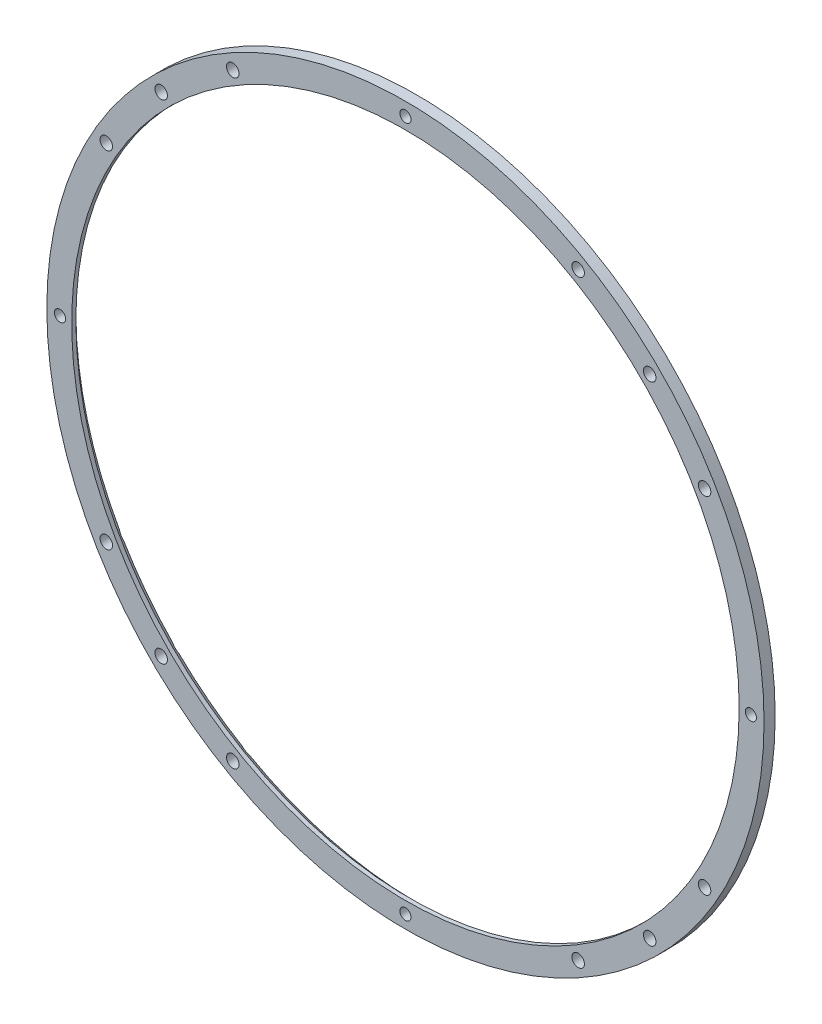
from build123d import *

# Parameters (mm, degrees)
F_4_5_4_5_DIAMETER_HOLE1_D = 4.5
CIRPATTERN1_COUNT          = 12
F_4_0_4_DIAMETER_HOLE1_D   = 4
CIRPATTERN2_COUNT          = 4
F_4_5_4_5_DIAMETER_HOLE2_D = 4.5
CIRPATTERN3_COUNT          = 4


with BuildPart() as part:
    # Sketch1 → Revolve1 (revolve)
    with BuildSketch(Plane(origin=(0, 0, 0), x_dir=(0, 0, -1), z_dir=(1, 0, 0)), mode=Mode.PRIVATE) as revolve1_sk:
        Polygon((0, 122.55), (-2.5, 120.05), (-4, 120.05), (-4, 129), (0, 129), align=None)
    revolve(revolve1_sk.sketch.rotate(Axis((0, 0, 27.349424097), (0, 0, -1)), 90), axis=Axis((0, 0, 27.349424097), (0, 0, -1)))  # turned: the seam where the file's is

    # Ø4.5 (4.5) Diameter Hole1 (through all)
    with Locations(Plane.XY.offset(4)):
        with Locations((62.125, 107.60365642)):
            f_4_5_4_5_diameter_hole1 = Hole(F_4_5_4_5_DIAMETER_HOLE1_D / 2)

    # CirPattern1: Ø4.5 (4.5) Diameter Hole1 ×12 about axis, 4 skipped
    cirpattern1_axis = Axis((0, 0, -80.9), (0, 0, 1))
    add([f_4_5_4_5_diameter_hole1.rotate(cirpattern1_axis, i * 360 / CIRPATTERN1_COUNT) for i in range(1, CIRPATTERN1_COUNT) if i not in (1, 4, 7, 10)], mode=Mode.SUBTRACT)

    # Ø4.0 (4) Diameter Hole1 (through all)
    with Locations(Plane.XY.offset(4)):
        with Locations((124.25, 0)):
            f_4_0_4_diameter_hole1 = Hole(F_4_0_4_DIAMETER_HOLE1_D / 2)

    # CirPattern2: Ø4.0 (4) Diameter Hole1 ×4 about axis
    cirpattern2_axis = Axis((0, 0, 0), (0, 0, 1))
    for i in range(1, CIRPATTERN2_COUNT):
        add(f_4_0_4_diameter_hole1.rotate(cirpattern2_axis, i * 360 / CIRPATTERN2_COUNT), mode=Mode.SUBTRACT)

    # Ø4.5 (4.5) Diameter Hole2 (through all)
    with Locations(Plane.XY.offset(4)):
        with Locations((87.858017562, 87.858017562)):
            f_4_5_4_5_diameter_hole2 = Hole(F_4_5_4_5_DIAMETER_HOLE2_D / 2)

    # CirPattern3: Ø4.5 (4.5) Diameter Hole2 ×4 about axis
    cirpattern3_axis = Axis((0, 0, 0), (0, 0, 1))
    for i in range(1, CIRPATTERN3_COUNT):
        add(f_4_5_4_5_diameter_hole2.rotate(cirpattern3_axis, i * 360 / CIRPATTERN3_COUNT), mode=Mode.SUBTRACT)


solid = part.part
